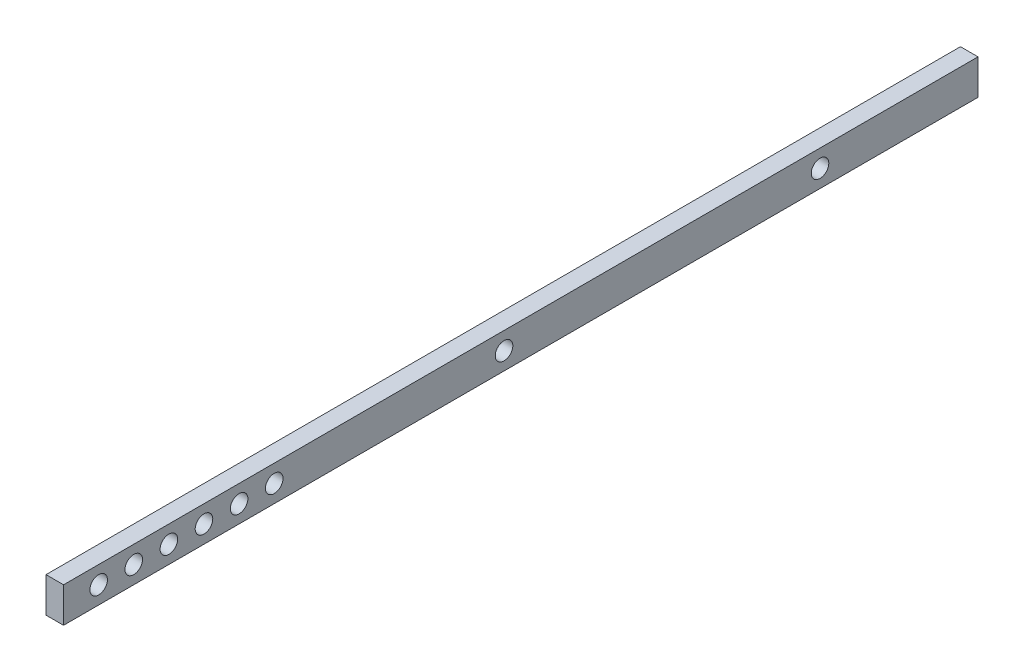
from build123d import *

# Parameters (mm, degrees)
SKETCH1_W           = 76.495
SKETCH1_H           = 6.35
SKETCH1_R           = 1.5875
SKETCH1_W_2         = 63.5
SKETCH1_W_3         = 25.4
BOSS_EXTRUDE1_DEPTH = 3.175


with BuildPart() as part:
    # Sketch1 → Boss-Extrude1 (new body)
    with BuildSketch(Plane(origin=(0, 0, 0), x_dir=(0, 0, -1), z_dir=(1, 0, 0))):
        with Locations((-38.2475, 3.175)):
            Rectangle(SKETCH1_W, SKETCH1_H)
        with Locations((-70.145, 3.175)):
            Circle(SKETCH1_R, mode=Mode.SUBTRACT)
        with Locations((-63.795, 3.175)):
            Circle(SKETCH1_R, mode=Mode.SUBTRACT)
        with Locations((-57.445, 3.175)):
            Circle(SKETCH1_R, mode=Mode.SUBTRACT)
        with Locations((-51.095, 3.175)):
            Circle(SKETCH1_R, mode=Mode.SUBTRACT)
        with Locations((-44.745, 3.175)):
            Circle(SKETCH1_R, mode=Mode.SUBTRACT)
        with Locations((-38.395, 3.175)):
            Circle(SKETCH1_R, mode=Mode.SUBTRACT)
        with Locations((31.75, 3.175)):
            Rectangle(SKETCH1_W_2, SKETCH1_H)
        with Locations((3.175, 3.175)):
            Circle(SKETCH1_R, mode=Mode.SUBTRACT)
        with Locations((60.325, 3.175)):
            Circle(SKETCH1_R, mode=Mode.SUBTRACT)
        with Locations((76.2, 3.175)):
            Rectangle(SKETCH1_W_3, SKETCH1_H)
    extrude(amount=BOSS_EXTRUDE1_DEPTH)


solid = part.part
